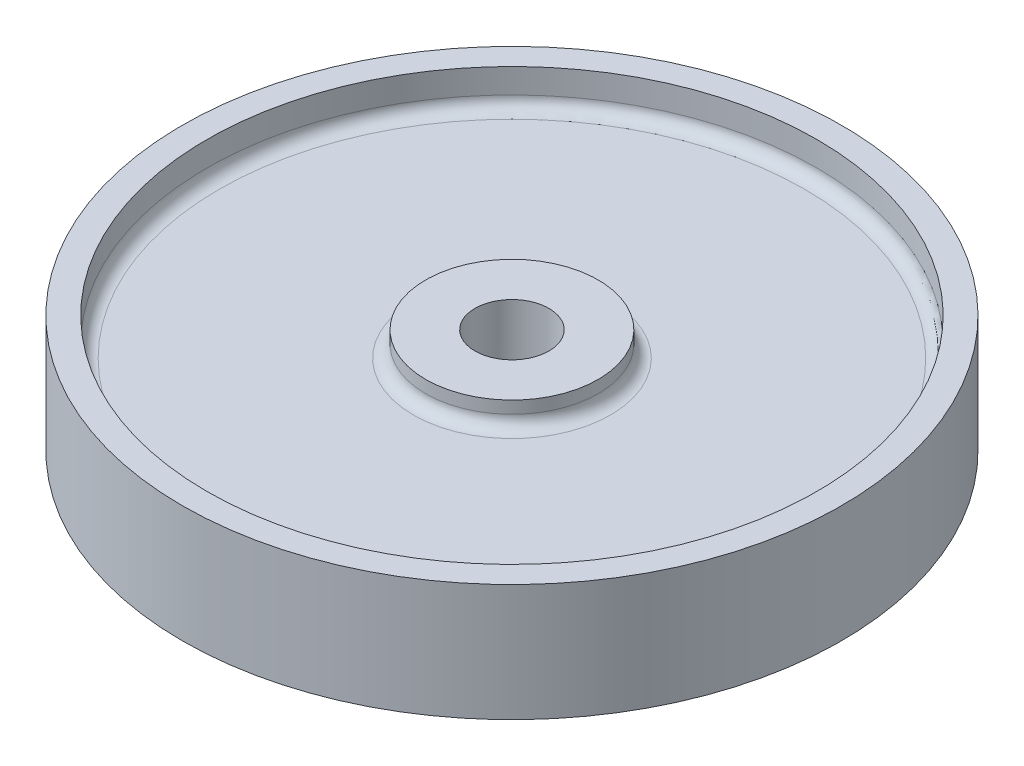
from build123d import *

# Parameters (mm, degrees)
SKETCH1_R            = 53.5
BOSS_EXTRUDE1_DEPTH  = 19
SKETCH2_R            = 49.5
CUT_EXTRUDE1_DEPTH   = 6
FILLET1_R            = 2
SKETCH3_R            = 14
BOSS_EXTRUDE2_DEPTH  = 4
FILLET2_R            = 2
FILLET1_OF_MIRROR1_R = 2
FILLET2_OF_MIRROR1_R = 2
SKETCH5_R            = 6
CUT_EXTRUDE2_DEPTH   = 18


with BuildPart() as part:
    # Sketch1 → Boss-Extrude1 (new body)
    with BuildSketch(Plane(origin=(0, 0, 0), x_dir=(1, 0, 0), z_dir=(0, 1, 0))):
        Circle(SKETCH1_R)
    extrude(amount=BOSS_EXTRUDE1_DEPTH)

    # Sketch2 → Cut-Extrude1 (cut)
    with BuildSketch(Plane(origin=(0, 19, 0), x_dir=(1, 0, 0), z_dir=(0, 1, 0))):
        Circle(SKETCH2_R)
    cut_extrude1 = extrude(amount=-CUT_EXTRUDE1_DEPTH, mode=Mode.SUBTRACT)

    # Fillet1
    fillet1_edges = [part.edges().sort_by_distance(p)[0] for p in [
        (-49.5, 13, 0),
    ]]
    fillet(fillet1_edges, radius=FILLET1_R)

    # Sketch3 → Boss-Extrude2 (add)
    with BuildSketch(Plane(origin=(0, 13, 0), x_dir=(1, 0, 0), z_dir=(0, 1, 0))):
        Circle(SKETCH3_R)
    boss_extrude2 = extrude(amount=BOSS_EXTRUDE2_DEPTH)

    # Fillet2
    fillet2_edges = [part.edges().sort_by_distance(p)[0] for p in [
        (-14, 13, 0),
    ]]
    fillet(fillet2_edges, radius=FILLET2_R)

    # Mirror1: Cut-Extrude1, Boss-Extrude2 across plane
    add(cut_extrude1.mirror(Plane.ZX.offset(9.5)), mode=Mode.SUBTRACT)
    add(boss_extrude2.mirror(Plane.ZX.offset(9.5)))

    # Fillet1 of Mirror1
    fillet1_of_mirror1_edges = [part.edges().sort_by_distance(p)[0] for p in [
        (-49.5, 6, 0),
    ]]
    fillet(fillet1_of_mirror1_edges, radius=FILLET1_OF_MIRROR1_R)

    # Fillet2 of Mirror1
    fillet2_of_mirror1_edges = [part.edges().sort_by_distance(p)[0] for p in [
        (-14, 6, 0),
    ]]
    fillet(fillet2_of_mirror1_edges, radius=FILLET2_OF_MIRROR1_R)

    # Sketch5 → Cut-Extrude2 (cut, through all)
    with BuildSketch(Plane(origin=(0, 17, 0), x_dir=(1, 0, 0), z_dir=(0, 1, 0))):
        Circle(SKETCH5_R)
    extrude(amount=-CUT_EXTRUDE2_DEPTH, mode=Mode.SUBTRACT)


solid = part.part
